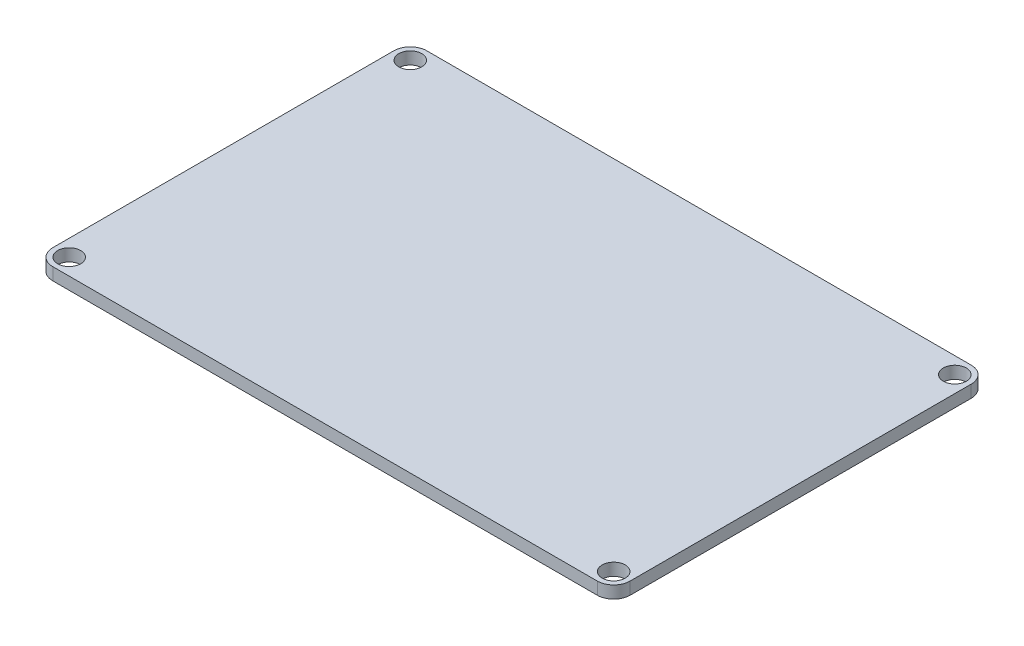
from build123d import *

# Parameters (mm, degrees)
SKETCH1_W                 = 134.5
SKETCH1_H                 = 85
BOSS_EXTRUDE1_DEPTH       = 3
SKETCH2_W                 = 140.5
SKETCH2_H                 = 91
SKETCH2_W_2               = 134.5
SKETCH2_H_2               = 85
BOSS_EXTRUDE2_DEPTH       = 70
BOSS_EXTRUDE3_START       = 5
SKETCH3_W                 = 100
SKETCH3_H                 = 80
BOSS_EXTRUDE3_DEPTH       = 5
SKETCH5_W                 = 3
SKETCH5_H                 = 66
BOSS_EXTRUDE5_DEPTH       = 30
SKETCH6_R                 = 3
SKETCH6_R_2               = 1
BOSS_EXTRUDE6_DEPTH       = 10
SKETCH7_W                 = 100
SKETCH7_H                 = 80
CUT_EXTRUDE2_DEPTH        = 10
SKETCH6_2_R               = 3
SKETCH6_2_R_2             = 1
BOSS_EXTRUDE7_DEPTH       = 8
MIRROR4_COPY_1_SKETCH_R   = 3
MIRROR4_COPY_1_SKETCH_R_2 = 1
MIRROR4_COPY_1_DEPTH      = 8
SKETCH9_R                 = 26.15
SKETCH9_W                 = 29.3
SKETCH9_H                 = 26.2
SKETCH9_R_2               = 1
SKETCH9_R_3               = 3.4
SKETCH9_R_4               = 7.9
CUT_EXTRUDE3_DEPTH        = 3
SKETCH10_R                = 2.95
SKETCH10_R_2              = 5.9
CUT_EXTRUDE4_DEPTH        = 3
BOSS_EXTRUDE8_DEPTH       = 7
FILLET1_R                 = 4
CUT_EXTRUDE6_DEPTH        = 5
SKETCH14_R                = 2.8
BOSS_EXTRUDE9_DEPTH       = 3


with BuildPart() as part:
    # Sketch1 → Boss-Extrude1 (new body)
    with BuildSketch(Plane(origin=(0, 0, 0), x_dir=(1, 0, 0), z_dir=(0, 1, 0))):
        with Locations((-12.25, 0)):
            Rectangle(SKETCH1_W, SKETCH1_H)
    extrude(amount=BOSS_EXTRUDE1_DEPTH)

    # Sketch2 → Boss-Extrude2 (add)
    with BuildSketch(Plane(origin=(0, 0, 0), x_dir=(1, 0, 0), z_dir=(0, 1, 0))):
        with Locations((-12.25, 0)):
            Rectangle(SKETCH2_W, SKETCH2_H)
        with Locations((-12.25, 0)):
            Rectangle(SKETCH2_W_2, SKETCH2_H_2, mode=Mode.SUBTRACT)
    extrude(amount=BOSS_EXTRUDE2_DEPTH)

    # Sketch5 → Boss-Extrude5 (add)
    with BuildSketch(Plane(origin=(0, 3, 0), x_dir=(1, 0, 0), z_dir=(0, 1, 0))):
        Polygon((-58, -26.5), (-58, -23.5), (-61, -23.5), (-79.5, -23.5), (-79.5, -26.5), align=None)
        with Locations((-59.5, 9.5)):
            Rectangle(SKETCH5_W, SKETCH5_H)
    extrude(amount=BOSS_EXTRUDE5_DEPTH)



with BuildPart() as body_2:
    # Sketch3 → Boss-Extrude3 (new body)
    with BuildSketch(Plane(origin=(0, 3, 0), x_dir=(1, 0, 0), z_dir=(0, 1, 0)).offset(BOSS_EXTRUDE3_START)):
        Rectangle(SKETCH3_W, SKETCH3_H)
    extrude(amount=BOSS_EXTRUDE3_DEPTH)


with BuildPart() as part_1:
    add(part.part)

    add(body_2.part)  # Boss-Extrude6 merges body 2
    # Sketch6 → Boss-Extrude6 (add)
    with BuildSketch(Plane(origin=(0, 3, 0), x_dir=(1, 0, 0), z_dir=(0, 1, 0))):
        with Locations((-45, -35)):
            Circle(SKETCH6_R)
        with Locations((-45, -35)):
            Circle(SKETCH6_R_2, mode=Mode.SUBTRACT)
    extrude(amount=BOSS_EXTRUDE6_DEPTH)

    # Sketch7 → Cut-Extrude2 (cut)
    with BuildSketch(Plane(origin=(0, 13, 0), x_dir=(1, 0, 0), z_dir=(0, 1, 0))):
        Rectangle(SKETCH7_W, SKETCH7_H)
    extrude(amount=-CUT_EXTRUDE2_DEPTH, mode=Mode.SUBTRACT)

    # Sketch6_2 → Boss-Extrude7 (add)
    with BuildSketch(Plane(origin=(0, 3, 0), x_dir=(1, 0, 0), z_dir=(0, 1, 0))):
        with Locations((-45, -35)):
            Circle(SKETCH6_2_R)
        with Locations((-45, -35)):
            Circle(SKETCH6_2_R_2, mode=Mode.SUBTRACT)
    boss_extrude7 = extrude(amount=BOSS_EXTRUDE7_DEPTH)

    # Mirror3: Boss-Extrude7 across plane
    add(boss_extrude7.mirror(Plane.XY))

    # Mirror4: Boss-Extrude7 across plane
    add(boss_extrude7.mirror(Plane(origin=(0, 0, 0), x_dir=(0, 0, 1), z_dir=(1, 0, 0))))

    # Mirror4 copy 1 sketch → Mirror4 copy 1 (add)
    with BuildSketch(Plane(origin=(0, 3, 0), x_dir=(-1, 0, 0), z_dir=(0, 1, 0))):
        with Locations((-45, -35)):
            Circle(MIRROR4_COPY_1_SKETCH_R)
        with Locations((-45, -35)):
            Circle(MIRROR4_COPY_1_SKETCH_R_2, mode=Mode.SUBTRACT)
    extrude(amount=MIRROR4_COPY_1_DEPTH)

    # Sketch9 → Cut-Extrude3 (cut)
    with BuildSketch(Plane.XY.offset(45.5)):
        with Locations((23, 40.85)):
            Circle(SKETCH9_R)
        with Locations((-47.5, 50)):
            Rectangle(SKETCH9_W, SKETCH9_H)
        with Locations((1.786796564, 62.063203436)):
            Circle(SKETCH9_R_2)
        with Locations((44.213203436, 62.063203436)):
            Circle(SKETCH9_R_2)
        with Locations((44.213203436, 19.636796564)):
            Circle(SKETCH9_R_2)
        with Locations((1.786796564, 19.636796564)):
            Circle(SKETCH9_R_2)
        with Locations((-58.75, 21.9)):
            Circle(SKETCH9_R_3)
        with Locations((-40.75, 21.9)):
            Circle(SKETCH9_R_4)
    extrude(amount=-CUT_EXTRUDE3_DEPTH, mode=Mode.SUBTRACT)

    # Sketch10 → Cut-Extrude4 (cut)
    with BuildSketch(Plane(origin=(58, 0, 0), x_dir=(0, 0, -1), z_dir=(1, 0, 0))):
        with Locations((15.5, 55)):
            Circle(SKETCH10_R)
        with Locations((30.5, 55)):
            Circle(SKETCH10_R_2)
    extrude(amount=-CUT_EXTRUDE4_DEPTH, mode=Mode.SUBTRACT)

    # Sketch11 → Boss-Extrude8 (add)
    with BuildSketch(Plane(origin=(0, 70, 0), x_dir=(1, 0, 0), z_dir=(0, 1, 0))):
        Polygon((-74.5, 42.5), (-79.5, 42.5), (-79.5, 37.5), align=None)
        Polygon((55, 37.5), (55, 42.5), (50, 42.5), align=None)
        Polygon((50, -42.5), (55, -42.5), (55, -37.5), align=None)
        Polygon((-79.5, -37.5), (-79.5, -42.5), (-74.5, -42.5), align=None)
    extrude(amount=-BOSS_EXTRUDE8_DEPTH)

    # Fillet1
    fillet1_edges = [part_1.edges().sort_by_distance(p)[0] for p in [
        (58, 35, 45.5),
        (58, 35, -45.5),
        (-82.5, 35, -45.5),
        (-82.5, 35, 45.5),
    ]]
    fillet(fillet1_edges, radius=FILLET1_R)

    # Sketch13 → Cut-Extrude6 (cut)
    with BuildSketch(Plane(origin=(0, 70, 0), x_dir=(1, 0, 0), z_dir=(0, 1, 0))):
        with BuildLine():
            ThreePointArc((55.371320344, 42.871320344), (53.957106781, 42.871320344), (53.957106781, 41.457106781))
            Line((53.957106781, 41.457106781), (55.371320344, 42.871320344))
        make_face()
        with BuildLine():
            Line((55.371320344, 42.871320344), (53.957106781, 41.457106781))
            ThreePointArc((53.957106781, 41.457106781), (55.046896995, 41.24033403), (55.664213562, 42.164213562))
            ThreePointArc((55.664213562, 42.164213562), (55.588093095, 42.546896995), (55.371320344, 42.871320344))
        make_face()
        with BuildLine():
            ThreePointArc((53.957106781, -41.457106781), (53.957106781, -42.871320344), (55.371320344, -42.871320344))
            Line((55.371320344, -42.871320344), (53.957106781, -41.457106781))
        make_face()
        with BuildLine():
            Line((53.957106781, -41.457106781), (55.371320344, -42.871320344))
            ThreePointArc((55.371320344, -42.871320344), (55.588093095, -42.546896995), (55.664213562, -42.164213562))
            ThreePointArc((55.664213562, -42.164213562), (55.046896995, -41.24033403), (53.957106781, -41.457106781))
        make_face()
        with BuildLine():
            ThreePointArc((-78.164213562, -42.164213562), (-78.24033403, -41.78153013), (-78.457106781, -41.457106781))
            Line((-78.457106781, -41.457106781), (-79.871320344, -42.871320344))
            ThreePointArc((-79.871320344, -42.871320344), (-78.78153013, -43.088093095), (-78.164213562, -42.164213562))
        make_face()
        with BuildLine():
            Line((-79.871320344, -42.871320344), (-78.457106781, -41.457106781))
            ThreePointArc((-78.457106781, -41.457106781), (-79.871320344, -41.457106781), (-79.871320344, -42.871320344))
        make_face()
        with BuildLine():
            ThreePointArc((-78.164213562, 42.164213562), (-78.78153013, 43.088093095), (-79.871320344, 42.871320344))
            Line((-79.871320344, 42.871320344), (-78.457106781, 41.457106781))
            ThreePointArc((-78.457106781, 41.457106781), (-78.24033403, 41.78153013), (-78.164213562, 42.164213562))
        make_face()
        with BuildLine():
            Line((-78.457106781, 41.457106781), (-79.871320344, 42.871320344))
            ThreePointArc((-79.871320344, 42.871320344), (-79.871320344, 41.457106781), (-78.457106781, 41.457106781))
        make_face()
    extrude(amount=-CUT_EXTRUDE6_DEPTH, mode=Mode.SUBTRACT)


with BuildPart() as body_2_2:
    # Sketch14 → Boss-Extrude9 (new body)
    with BuildSketch(Plane(origin=(0, 70, 0), x_dir=(1, 0, 0), z_dir=(0, 1, 0))):
        with BuildLine():
            Line((-78.5, -45.5), (54, -45.5))
            ThreePointArc((54, -45.5), (56.828427125, -44.328427125), (58, -41.5))
            Line((58, -41.5), (58, 41.5))
            ThreePointArc((58, 41.5), (56.828427125, 44.328427125), (54, 45.5))
            Line((54, 45.5), (-78.5, 45.5))
            ThreePointArc((-78.5, 45.5), (-81.328427125, 44.328427125), (-82.5, 41.5))
            Line((-82.5, 41.5), (-82.5, -41.5))
            ThreePointArc((-82.5, -41.5), (-81.328427125, -44.328427125), (-78.5, -45.5))
        make_face()
        with Locations((-78.5, 41.5)):
            Circle(SKETCH14_R, mode=Mode.SUBTRACT)
        with Locations((54, 41.5)):
            Circle(SKETCH14_R, mode=Mode.SUBTRACT)
        with Locations((54, -41.5)):
            Circle(SKETCH14_R, mode=Mode.SUBTRACT)
        with Locations((-78.5, -41.5)):
            Circle(SKETCH14_R, mode=Mode.SUBTRACT)
    extrude(amount=BOSS_EXTRUDE9_DEPTH)


solid = body_2_2.part
